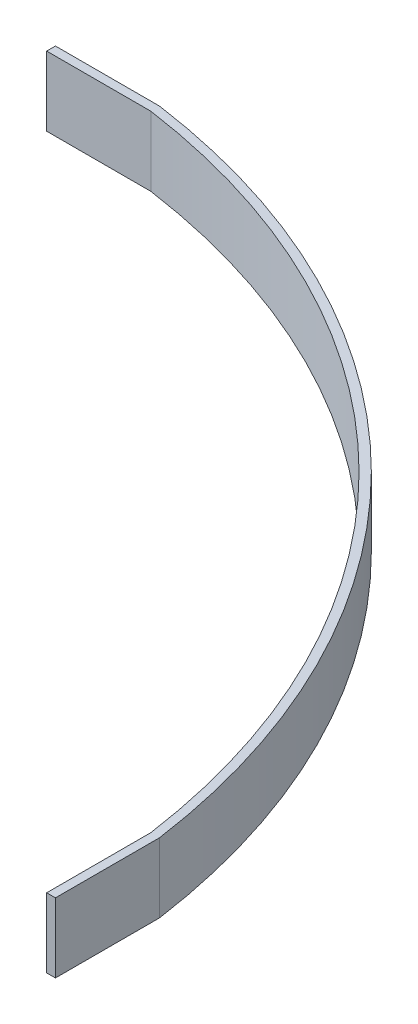
from build123d import *

# Parameters (mm, degrees)
BOSS_EXTRUDE1_DEPTH = 12.7


with BuildPart() as part:
    # Sketch1 → Boss-Extrude1 (new body)
    with BuildSketch(Plane(origin=(0, 0, 0), x_dir=(1, 0, 0), z_dir=(0, 1, 0))):
        with BuildLine():
            ThreePointArc((19.05, 134.953426611), (96.372532015, 96.372532015), (134.953426611, 19.05))
            Line((134.953426611, 19.05), (134.953426611, 0))
            Line((134.953426611, 0), (133.35, 0))
            Line((133.35, 0), (133.35, 19.05))
            ThreePointArc((133.35, 19.05), (95.25, 95.25), (19.05, 133.35))
            Line((19.05, 133.35), (0, 133.35))
            Line((0, 133.35), (0, 134.953426611))
            Line((0, 134.953426611), (19.05, 134.953426611))
        make_face()
    extrude(amount=BOSS_EXTRUDE1_DEPTH)


solid = part.part
